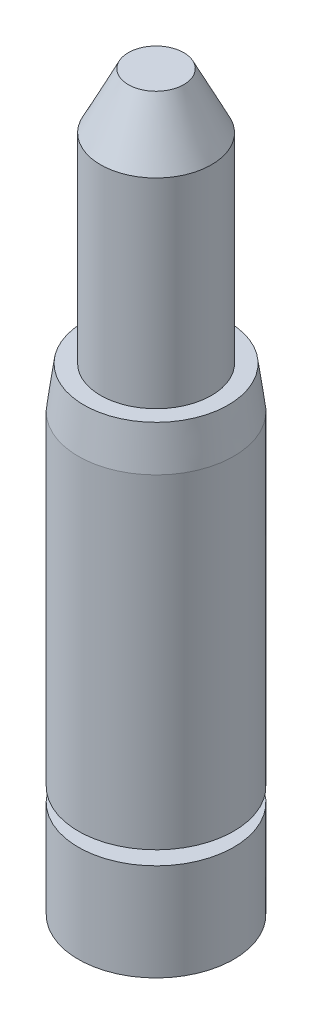
from build123d import *


with BuildPart() as part:
    # Sketch1 → Revolve1 (revolve)
    with BuildSketch(Plane.XY):
        Polygon((0, 0), (0, 167.64), (6.35, 167.64), (12.7, 154.94), (12.7, 109.22), (16.51, 109.22), (17.78, 99.695), (17.78, 25.4), (12.7, 25.4), (12.7, 22.225), (17.78, 22.225), (17.78, 0), align=None)
    revolve(axis=Axis((0, 0, 0), (0, 1, 0)))


solid = part.part
